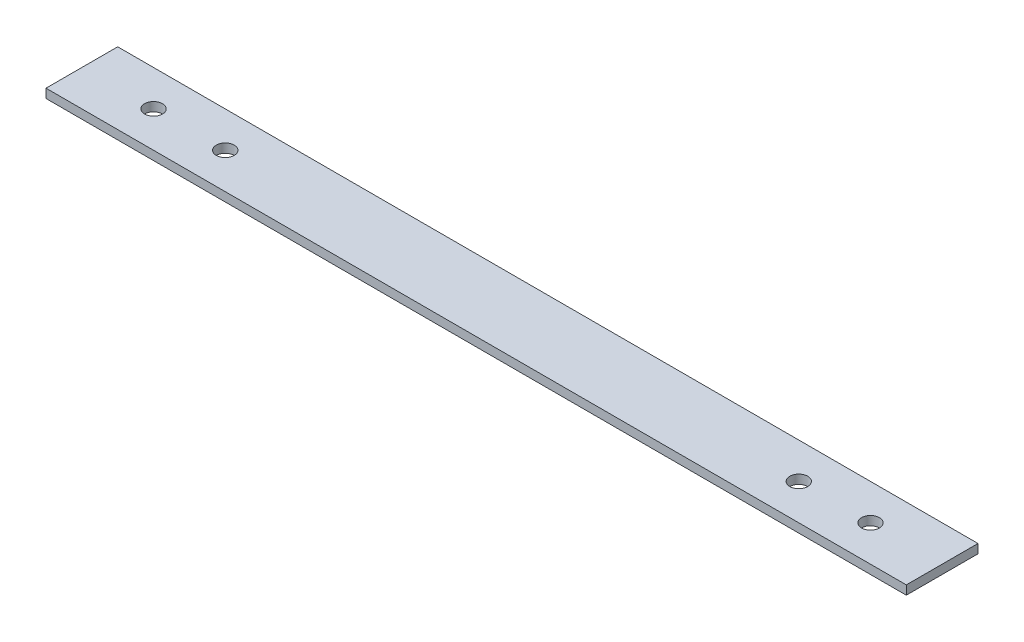
from build123d import *

# Parameters (mm, degrees)
SKETCH1_W           = 609.6
SKETCH1_H           = 50.8
BOSS_EXTRUDE1_DEPTH = 6.35
SKETCH2_R           = 6.35
CUT_EXTRUDE1_DEPTH  = 7.35


with BuildPart() as part:
    # Sketch1 → Boss-Extrude1 (new body)
    with BuildSketch(Plane(origin=(0, 0, 0), x_dir=(1, 0, 0), z_dir=(0, 1, 0))):
        with Locations((304.8, 25.4)):
            Rectangle(SKETCH1_W, SKETCH1_H)
    extrude(amount=BOSS_EXTRUDE1_DEPTH)

    # Sketch2 → Cut-Extrude1 (cut, through all)
    with BuildSketch(Plane(origin=(0, 6.35, 0), x_dir=(1, 0, 0), z_dir=(0, 1, 0))):
        with Locations((558.8, 25.4)):
            Circle(SKETCH2_R)
        with Locations((50.8, 25.4)):
            Circle(SKETCH2_R)
        with Locations((101.6, 25.4)):
            Circle(SKETCH2_R)
        with Locations((508, 25.4)):
            Circle(SKETCH2_R)
    extrude(amount=-CUT_EXTRUDE1_DEPTH, mode=Mode.SUBTRACT)


solid = part.part
